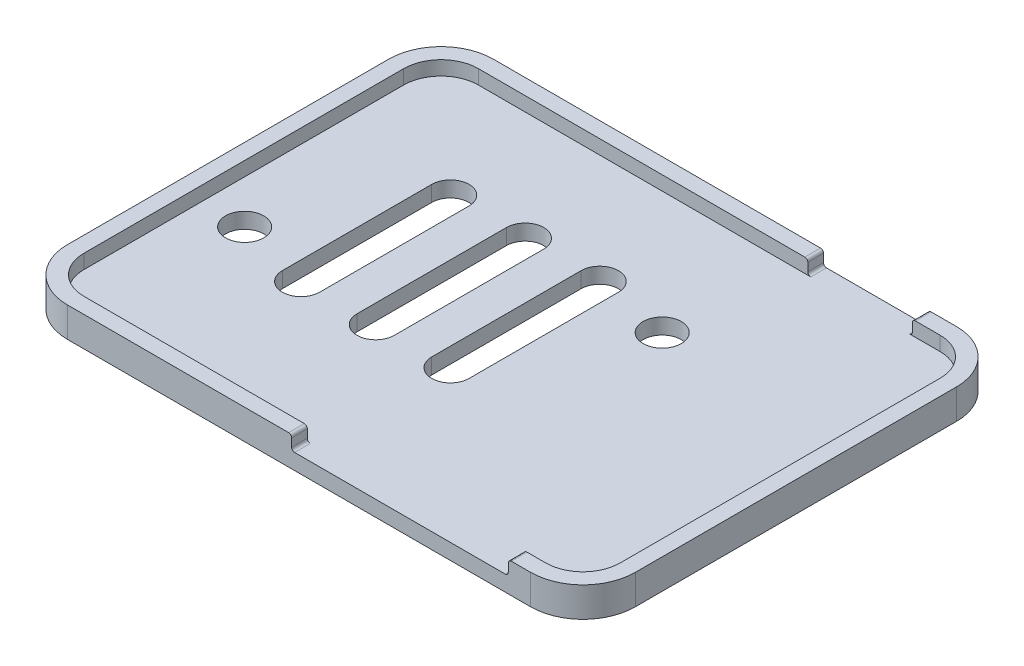
from build123d import *

# Parameters (mm, degrees)
SKETCH1_W           = 96.52
SKETCH1_H           = 72.39
BOSS_EXTRUDE1_DEPTH = 5.08
SHELL1_T            = -2.667
FILLET1_R           = 6.35
FILLET2_R           = 8.89
SKETCH2_W           = 36.83
SKETCH2_H           = 2.413
CUT_EXTRUDE1_DEPTH  = 5.08
SKETCH3_W           = 17.78
SKETCH3_H           = 2.413
CUT_EXTRUDE2_DEPTH  = 5.08
FILLET3_R           = 0.508
CUT_EXTRUDE3_REACH  = 7.08
SKETCH4_R           = 3.25
CUT_EXTRUDE4_DEPTH  = 6.08


with BuildPart() as part:
    # Sketch1 → Boss-Extrude1 (new body)
    with BuildSketch(Plane(origin=(0, 0, 0), x_dir=(1, 0, 0), z_dir=(0, 1, 0))):
        Rectangle(SKETCH1_W, SKETCH1_H)
    extrude(amount=BOSS_EXTRUDE1_DEPTH)

    # Shell1
    shell1_openings = [part.faces().sort_by_distance(p)[0] for p in [
        (0, 5.08, 0),
    ]]
    offset(amount=SHELL1_T, openings=shell1_openings, kind=Kind.INTERSECTION)

    # Fillet1
    fillet1_edges = [part.edges().sort_by_distance(p)[0] for p in [
        (45.593, 3.8735, 33.528),
        (45.593, 3.8735, -33.528),
        (-45.593, 3.8735, -33.528),
        (-45.593, 3.8735, 33.528),
    ]]
    fillet(fillet1_edges, radius=FILLET1_R)

    # Fillet2
    fillet2_edges = [part.edges().sort_by_distance(p)[0] for p in [
        (48.26, 2.54, 36.195),
        (-48.26, 2.54, 36.195),
        (-48.26, 2.54, -36.195),
        (48.26, 2.54, -36.195),
    ]]
    fillet(fillet2_edges, radius=FILLET2_R)

    # Sketch2 → Cut-Extrude1 (cut)
    with BuildSketch(Plane.XY.offset(36.195)):
        with Locations((17.145, 3.8735)):
            Rectangle(SKETCH2_W, SKETCH2_H)
    extrude(amount=-CUT_EXTRUDE1_DEPTH, mode=Mode.SUBTRACT)

    # Sketch3 → Cut-Extrude2 (cut)
    with BuildSketch(Plane(origin=(0, 0, -36.195), x_dir=(-1, 0, 0), z_dir=(0, 0, -1))):
        with Locations((-25.654, 3.8735)):
            Rectangle(SKETCH3_W, SKETCH3_H)
    extrude(amount=-CUT_EXTRUDE2_DEPTH, mode=Mode.SUBTRACT)

    # Fillet3
    fillet3_edges = [part.edges().sort_by_distance(p)[0] for p in [
        (34.544, 2.667, -34.8615),
        (34.544, 5.08, -34.8615),
        (16.764, 5.08, -34.8615),
        (16.764, 2.667, -34.8615),
        (35.56, 5.08, 34.8615),
        (35.56, 2.667, 34.8615),
        (-1.27, 2.667, 34.8615),
        (-1.27, 5.08, 34.8615),
    ]]
    fillet(fillet3_edges, radius=FILLET3_R)

    # Sketch4 → Cut-Extrude3 (cut, up to next)
    with BuildSketch(Plane.XZ, mode=Mode.PRIVATE) as cut_extrude3_sk1:
        with Locations((-38.231636466, 7.223235777)):
            Circle(SKETCH4_R)
    cut_extrude3_tool1 = extrude(cut_extrude3_sk1.sketch, amount=-CUT_EXTRUDE3_REACH, mode=Mode.PRIVATE) & part.part
    add(cut_extrude3_tool1.solids().sort_by_distance((-38.231636, 0, 7.223236))[0], mode=Mode.SUBTRACT)
    # Sketch4 → Cut-Extrude3 (cut, up to next)
    with BuildSketch(Plane.XZ, mode=Mode.PRIVATE) as cut_extrude3_sk2:
        with Locations((12.830494848, -12.70407972)):
            Circle(SKETCH4_R)
    cut_extrude3_tool2 = extrude(cut_extrude3_sk2.sketch, amount=-CUT_EXTRUDE3_REACH, mode=Mode.PRIVATE) & part.part
    add(cut_extrude3_tool2.solids().sort_by_distance((12.830495, 0, -12.70408))[0], mode=Mode.SUBTRACT)

    # Sketch5 → Cut-Extrude4 (cut, through all)
    with BuildSketch(Plane.XZ):
        with BuildLine():
            Line((-9.530108749, 10.470046155), (-9.530108749, -14.929953845))
            ThreePointArc((-9.530108749, -14.929953845), (-12.705108749, -18.104953845), (-15.880108749, -14.929953845))
            Line((-15.880108749, -14.929953845), (-15.880108749, 10.470046155))
            ThreePointArc((-15.880108749, 10.470046155), (-12.705108749, 13.645046155), (-9.530108749, 10.470046155))
        make_face()
        with BuildLine():
            Line((3.169891251, 10.470046155), (3.169891251, -14.929953845))
            ThreePointArc((3.169891251, -14.929953845), (-0.005108749, -18.104953845), (-3.180108749, -14.929953845))
            Line((-3.180108749, -14.929953845), (-3.180108749, 10.470046155))
            ThreePointArc((-3.180108749, 10.470046155), (-0.005108749, 13.645046155), (3.169891251, 10.470046155))
        make_face()
        with BuildLine():
            Line((-22.230108749, 10.470046155), (-22.230108749, -14.929953845))
            ThreePointArc((-22.230108749, -14.929953845), (-25.405108749, -18.104953845), (-28.580108749, -14.929953845))
            Line((-28.580108749, -14.929953845), (-28.580108749, 10.470046155))
            ThreePointArc((-28.580108749, 10.470046155), (-25.405108749, 13.645046155), (-22.230108749, 10.470046155))
        make_face()
    extrude(amount=-CUT_EXTRUDE4_DEPTH, mode=Mode.SUBTRACT)


solid = part.part
